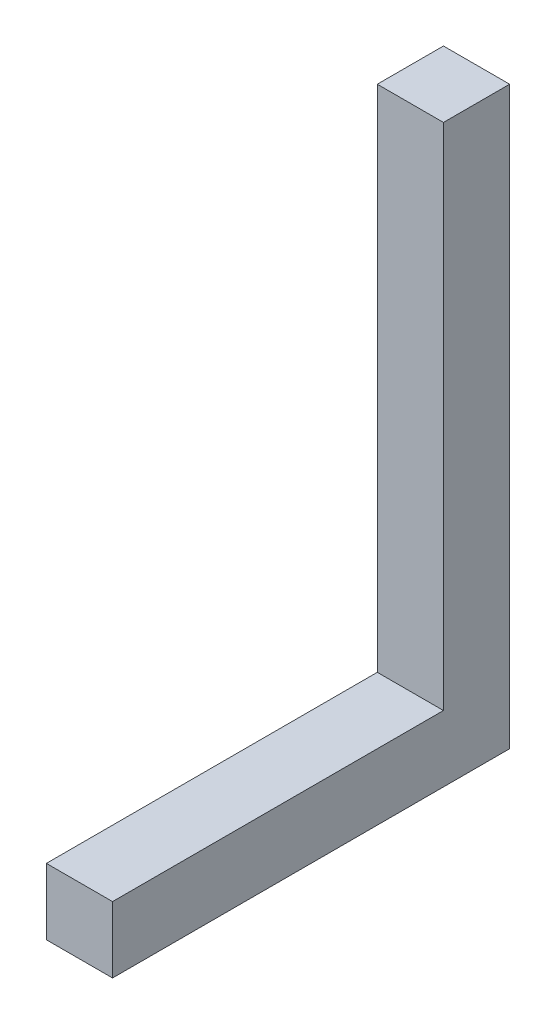
from build123d import *

# Parameters (mm, degrees)
SKETCH1_W           = 11.5
SKETCH1_H           = 11.5
BOSS_EXTRUDE1_DEPTH = 57.5
BOSS_EXTRUDE2_START = -5.75
SKETCH2_W           = 11.5
SKETCH2_H           = 11.5
BOSS_EXTRUDE2_DEPTH = 100


with BuildPart() as part:
    # Sketch1 → Boss-Extrude1 (new body)
    with BuildSketch(Plane.XY):
        Rectangle(SKETCH1_W, SKETCH1_H)
    extrude(amount=BOSS_EXTRUDE1_DEPTH)

    # Sketch2 → Boss-Extrude2 (add)
    with BuildSketch(Plane(origin=(0, 0, 0), x_dir=(1, 0, 0), z_dir=(0, 1, 0)).offset(BOSS_EXTRUDE2_START)):
        with Locations((0, 5.75)):
            Rectangle(SKETCH2_W, SKETCH2_H)
    extrude(amount=BOSS_EXTRUDE2_DEPTH)


solid = part.part
